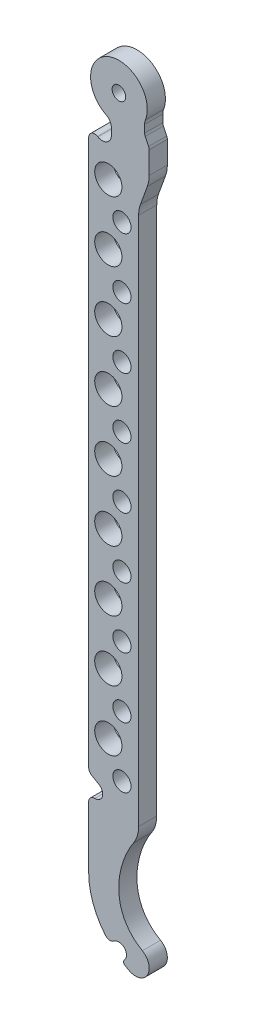
from build123d import *

# Parameters (mm, degrees)
EXTRUDE_1_DEPTH     = 6
CUT_EXTRUDE_1_DEPTH = 7.0000001
HOLE_WIZARD_M41_D   = 4.5
CUT_EXTRUDE_2_DEPTH = 7.0000001
SKETCH_9_R          = 3
SKETCH_9_R_2        = 4.5
CUT_EXTRUDE_4_DEPTH = 7.0000001
CUT_EXTRUDE_6_DEPTH = 7.0000001
FILLET_4_R          = 2
FILLET_5_R          = 10
FILLET_6_R          = 1
FILLET_7_R          = 3


with BuildPart() as part:
    # Эскиз1 → Бобышка-Вытянуть1 (new body)
    with BuildSketch(Plane.XY):
        with BuildLine():
            Line((6.5, -30), (6.5, -210))
            add(Edge.make_bspline(
                [(7.75, -241.602885683), (-4.554007881, -234.499163421), (-0.209884915, -217.844238119), (6.5, -210)],
                knots=[0, 0, 0, 0, 1, 1, 1, 1], degree=3))
            ThreePointArc((7.75, -241.602885683), (9.397114317, -247.75), (3.25, -249.397114317))
            ThreePointArc((3.25, -249.397114317), (1.977735046, -248.713449013), (0.749010369, -247.954310008))
            Line((0.749010369, -247.954310008), (1.25, -247.665063509))
            ThreePointArc((1.25, -247.665063509), (2.165063509, -244.25), (-1.25, -243.334936491))
            Line((-1.25, -243.334936491), (-3.342048726, -244.542781386))
            ThreePointArc((-3.342048726, -244.542781386), (-8.273241088, -236.903089302), (-10, -227.975611669))
            Line((-10, -227.975611669), (-10, 0))
            ThreePointArc((-10, 0), (0, 10), (10, 0))
            Line((10, 0), (10, -20.383829032))
            Line((10, -20.383829032), (6.5, -30))
        make_face()
    extrude(amount=EXTRUDE_1_DEPTH)

    # Эскиз2 → Вырез-Вытянуть1 (cut, through all)
    with BuildSketch(Plane.XY.offset(6)):
        with BuildLine():
            Line((-6.59421021, -201.178331294), (-10, -199.211997642))
            Line((-10, -199.211997642), (-10, -204.985500334))
            Line((-10, -204.985500334), (-9.09421021, -205.508458313))
            ThreePointArc((-9.09421021, -205.508458313), (-5.6791467, -204.593394804), (-6.59421021, -201.178331294))
        make_face()
    extrude(amount=-CUT_EXTRUDE_1_DEPTH, mode=Mode.SUBTRACT)

    # Отверстие с зазором M41 (through all)
    with Locations(Plane.XY.offset(6)):
        with Locations((0, 0)):
            Hole(HOLE_WIZARD_M41_D / 2)

    # Эскиз6 → Вырез-Вытянуть2 (cut, through all)
    with BuildSketch(Plane.XY.offset(6)):
        with BuildLine():
            ThreePointArc((8.758748453, -3.313367558), (-3.216437094, 8.794805936), (-4.554549196, -8.182307784))
            ThreePointArc((-4.554549196, -8.182307784), (-3.004971936, -13.622786652), (-8.445450804, -15.172363912))
            ThreePointArc((-8.445450804, -15.172363912), (-5.964204156, 16.308112544), (16.241251547, -6.143941255))
            ThreePointArc((16.241251547, -6.143941255), (11.084713151, -8.469905953), (8.758748453, -3.313367558))
        make_face()
    extrude(amount=-CUT_EXTRUDE_2_DEPTH, mode=Mode.SUBTRACT)

    # Эскиз9 → Вырез-Вытянуть4 (cut, through all)
    with BuildSketch(Plane.XY.offset(6)):
        with Locations((1, -36.464522083)):
            Circle(SKETCH_9_R)
        with Locations((1, -56.464522083)):
            Circle(SKETCH_9_R)
        with Locations((1, -76.464522083)):
            Circle(SKETCH_9_R)
        with Locations((1, -96.464522083)):
            Circle(SKETCH_9_R)
        with Locations((1, -116.464522083)):
            Circle(SKETCH_9_R)
        with Locations((1, -136.464522083)):
            Circle(SKETCH_9_R)
        with Locations((1, -156.464522083)):
            Circle(SKETCH_9_R)
        with Locations((1, -176.464522083)):
            Circle(SKETCH_9_R)
        with Locations((1, -196.464522083)):
            Circle(SKETCH_9_R)
        with Locations((-3.5, -26.464522083)):
            Circle(SKETCH_9_R_2)
        with Locations((-3.5, -46.464522083)):
            Circle(SKETCH_9_R_2)
        with Locations((-3.5, -66.464522083)):
            Circle(SKETCH_9_R_2)
        with Locations((-3.5, -86.464522083)):
            Circle(SKETCH_9_R_2)
        with Locations((-3.5, -106.464522083)):
            Circle(SKETCH_9_R_2)
        with Locations((-3.5, -126.464522083)):
            Circle(SKETCH_9_R_2)
        with Locations((-3.5, -146.464522083)):
            Circle(SKETCH_9_R_2)
        with Locations((-3.5, -166.464522083)):
            Circle(SKETCH_9_R_2)
        with Locations((-3.5, -186.464522083)):
            Circle(SKETCH_9_R_2)
    extrude(amount=-CUT_EXTRUDE_4_DEPTH, mode=Mode.SUBTRACT)

    # Эскиз11 → Вырез-Вытянуть6 (cut, through all)
    with BuildSketch(Plane.XY.offset(6)):
        Polygon((-2.5, -9.32593934), (-2.5, -18.481802874), (-10, -14.307049262), (-10, -5.151185729), align=None)
        Polygon((10, -7.851153406), (10, -10.804179155), (8.5, -7.681680155), (8.5, -4.728654406), align=None)
    extrude(amount=-CUT_EXTRUDE_6_DEPTH, mode=Mode.SUBTRACT)

    # Скругление4
    fillet_4_edges = [part.edges().sort_by_distance(p)[0] for p in [
        (-3.342048726, -244.542781386, 3),
        (-10, -204.985500334, 3),
        (-10, -199.211997642, 3),
        (8.5, -7.681680155, 3),
        (-10, -14.307049262, 3),
        (10, -10.804179155, 3),
    ]]
    fillet(fillet_4_edges, radius=FILLET_4_R)

    # Скругление5
    fillet_5_edges = [part.edges().sort_by_distance(p)[0] for p in [
        (6.5, -30, 3),
        (6.5, -210, 3),
        (10, -20.383829032, 3),
    ]]
    fillet(fillet_5_edges, radius=FILLET_5_R)

    # Скругление6
    fillet_6_edges = [part.edges().sort_by_distance(p)[0] for p in [
        (0.749010369, -247.954310008, 3),
    ]]
    fillet(fillet_6_edges, radius=FILLET_6_R)

    # Скругление7
    fillet_7_edges = [part.edges().sort_by_distance(p)[0] for p in [
        (-2.5, -9.32593934, 3),
        (-2.5, -18.481802874, 3),
    ]]
    fillet(fillet_7_edges, radius=FILLET_7_R)


solid = part.part
